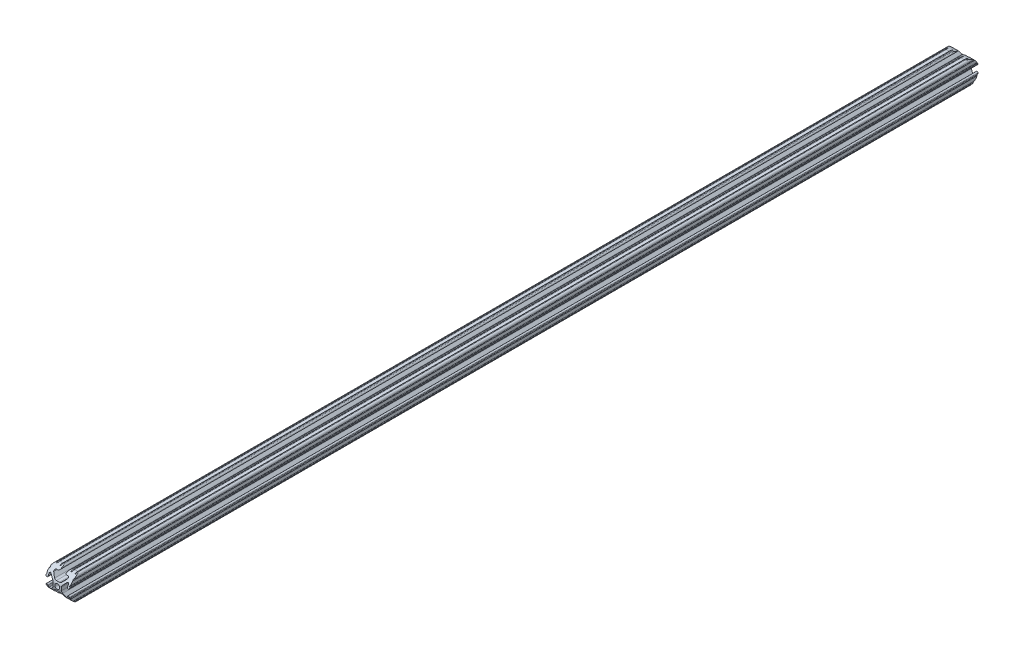
from build123d import *

# Parameters (mm, degrees)
SKETCH1_R           = 2.6035
BOSS_EXTRUDE1_DEPTH = 490.22
CUT_EXTRUDE1_DEPTH  = 26.4


with BuildPart() as part:
    # Sketch1 → Boss-Extrude1 (new body, symmetric)
    with BuildSketch(Plane(origin=(0, 0, -450.85), x_dir=(-1, 0, 0), z_dir=(0, 0, -1))):
        with BuildLine():
            Line((12.7, -9.5504), (12.7, -6.3330836))
            ThreePointArc((12.7, -6.3330836), (12.192, -5.8250836), (12.7, -5.3170836))
            Line((12.7, -5.3170836), (12.7, -4.3434))
            ThreePointArc((12.7, -4.3434), (11.5951, -3.2385), (10.4902, -4.3434))
            Line((10.4902, -4.3434), (10.4902, -6.474794456))
            ThreePointArc((10.4902, -6.474794456), (9.863006367, -7.413456061), (8.75577951, -7.193214945))
            Line((8.75577951, -7.193214945), (5.42573597, -3.863171405))
            ThreePointArc((5.42573597, -3.863171405), (4.737482484, -2.833127272), (4.4958, -1.618107374))
            Line((4.4958, -1.618107374), (4.4958, 1.618107374))
            ThreePointArc((4.4958, 1.618107374), (4.737482484, 2.833127272), (5.42573597, 3.863171405))
            Line((5.42573597, 3.863171405), (8.75577951, 7.193214945))
            ThreePointArc((8.75577951, 7.193214945), (9.863006367, 7.413456061), (10.4902, 6.474794456))
            Line((10.4902, 6.474794456), (10.4902, 4.343399971))
            ThreePointArc((10.4902, 4.343399971), (11.5951, 3.238499971), (12.7, 4.343399971))
            Line((12.7, 4.343399971), (12.7, 5.3170836))
            ThreePointArc((12.7, 5.3170836), (12.192, 5.8250836), (12.7, 6.3330836))
            Line((12.7, 6.3330836), (12.7, 9.5504))
            ThreePointArc((12.7, 9.5504), (12.192000006, 10.058323491), (12.699846982, 10.566399977))
            ThreePointArc((12.699846982, 10.566399977), (12.082522516, 12.082522516), (10.566399977, 12.699846982))
            ThreePointArc((10.566399977, 12.699846982), (10.058323491, 12.192000006), (9.5504, 12.7))
            Line((9.5504, 12.7), (6.3330836, 12.7))
            ThreePointArc((6.3330836, 12.7), (5.8250836, 12.192), (5.3170836, 12.7))
            Line((5.3170836, 12.7), (4.3434, 12.7))
            ThreePointArc((4.3434, 12.7), (3.2385, 11.5951), (4.3434, 10.4902))
            Line((4.3434, 10.4902), (6.474794456, 10.4902))
            ThreePointArc((6.474794456, 10.4902), (7.413456061, 9.863006367), (7.193214945, 8.75577951))
            Line((7.193214945, 8.75577951), (3.863171405, 5.42573597))
            ThreePointArc((3.863171405, 5.42573597), (2.833127272, 4.737482484), (1.618107374, 4.4958))
            Line((1.618107374, 4.4958), (-1.618107374, 4.4958))
            ThreePointArc((-1.618107374, 4.4958), (-2.833127272, 4.737482484), (-3.863171405, 5.42573597))
            Line((-3.863171405, 5.42573597), (-7.193214945, 8.75577951))
            ThreePointArc((-7.193214945, 8.75577951), (-7.413456061, 9.863006367), (-6.474794456, 10.4902))
            Line((-6.474794456, 10.4902), (-4.343399971, 10.4902))
            ThreePointArc((-4.343399971, 10.4902), (-3.238499971, 11.5951), (-4.343399971, 12.7))
            Line((-4.343399971, 12.7), (-5.3170836, 12.7))
            ThreePointArc((-5.3170836, 12.7), (-5.8250836, 12.192), (-6.3330836, 12.7))
            Line((-6.3330836, 12.7), (-9.5504, 12.7))
            ThreePointArc((-9.5504, 12.7), (-10.058323491, 12.192000006), (-10.566399977, 12.699846982))
            ThreePointArc((-10.566399977, 12.699846982), (-12.082522516, 12.082522516), (-12.699846982, 10.566399977))
            ThreePointArc((-12.699846982, 10.566399977), (-12.192000006, 10.058323491), (-12.7, 9.5504))
            Line((-12.7, 9.5504), (-12.7, 6.3330836))
            ThreePointArc((-12.7, 6.3330836), (-12.192, 5.8250836), (-12.7, 5.3170836))
            Line((-12.7, 5.3170836), (-12.7, 4.3434))
            ThreePointArc((-12.7, 4.3434), (-11.5951, 3.2385), (-10.4902, 4.3434))
            Line((-10.4902, 4.3434), (-10.4902, 6.474794456))
            ThreePointArc((-10.4902, 6.474794456), (-9.863006367, 7.413456061), (-8.75577951, 7.193214945))
            Line((-8.75577951, 7.193214945), (-5.42573597, 3.863171405))
            ThreePointArc((-5.42573597, 3.863171405), (-4.737482484, 2.833127272), (-4.4958, 1.618107374))
            Line((-4.4958, 1.618107374), (-4.4958, -1.618107374))
            ThreePointArc((-4.4958, -1.618107374), (-4.737482484, -2.833127272), (-5.42573597, -3.863171405))
            Line((-5.42573597, -3.863171405), (-8.75577951, -7.193214945))
            ThreePointArc((-8.75577951, -7.193214945), (-9.863006367, -7.413456061), (-10.4902, -6.474794456))
            Line((-10.4902, -6.474794456), (-10.4902, -4.343399971))
            ThreePointArc((-10.4902, -4.343399971), (-11.5951, -3.238499971), (-12.7, -4.343399971))
            Line((-12.7, -4.343399971), (-12.7, -5.3170836))
            ThreePointArc((-12.7, -5.3170836), (-12.192, -5.8250836), (-12.7, -6.3330836))
            Line((-12.7, -6.3330836), (-12.7, -9.5504))
            ThreePointArc((-12.7, -9.5504), (-12.192000006, -10.058323491), (-12.699846982, -10.566399977))
            ThreePointArc((-12.699846982, -10.566399977), (-12.082522516, -12.082522516), (-10.566399977, -12.699846982))
            ThreePointArc((-10.566399977, -12.699846982), (-10.058323491, -12.192000006), (-9.5504, -12.7))
            Line((-9.5504, -12.7), (-6.3330836, -12.7))
            ThreePointArc((-6.3330836, -12.7), (-5.8250836, -12.192), (-5.3170836, -12.7))
            Line((-5.3170836, -12.7), (-4.3434, -12.7))
            ThreePointArc((-4.3434, -12.7), (-3.2385, -11.5951), (-4.3434, -10.4902))
            Line((-4.3434, -10.4902), (-6.474794456, -10.4902))
            ThreePointArc((-6.474794456, -10.4902), (-7.413456061, -9.863006367), (-7.193214945, -8.75577951))
            Line((-7.193214945, -8.75577951), (-3.863171405, -5.42573597))
            ThreePointArc((-3.863171405, -5.42573597), (-2.833127272, -4.737482484), (-1.618107374, -4.4958))
            Line((-1.618107374, -4.4958), (1.618107374, -4.4958))
            ThreePointArc((1.618107374, -4.4958), (2.833127272, -4.737482484), (3.863171405, -5.42573597))
            Line((3.863171405, -5.42573597), (7.193214945, -8.75577951))
            ThreePointArc((7.193214945, -8.75577951), (7.413456061, -9.863006367), (6.474794456, -10.4902))
            Line((6.474794456, -10.4902), (4.343399971, -10.4902))
            ThreePointArc((4.343399971, -10.4902), (3.238499971, -11.5951), (4.343399971, -12.7))
            Line((4.343399971, -12.7), (5.3170836, -12.7))
            ThreePointArc((5.3170836, -12.7), (5.8250836, -12.192), (6.3330836, -12.7))
            Line((6.3330836, -12.7), (9.5504, -12.7))
            ThreePointArc((9.5504, -12.7), (10.058323491, -12.192000006), (10.566399977, -12.699846982))
            ThreePointArc((10.566399977, -12.699846982), (12.082522516, -12.082522516), (12.699846982, -10.566399977))
            ThreePointArc((12.699846982, -10.566399977), (12.192000006, -10.058323491), (12.7, -9.5504))
        make_face()
        Circle(SKETCH1_R, mode=Mode.SUBTRACT)
    extrude(amount=BOSS_EXTRUDE1_DEPTH, both=True)

    # Sketch2 → Cut-Extrude1 (cut, through all)
    with BuildSketch(Plane(origin=(12.7, 0, 0), x_dir=(0, 0, -1), z_dir=(1, 0, 0))):
        with BuildLine():
            Line((-26.773657599, 12.699846982), (-26.773657599, 15.407427294))
            Line((-26.773657599, 15.407427294), (-42.72426581, 14.835805087))
            Line((-42.72426581, 14.835805087), (-41.696320788, -13.848084546))
            Line((-41.696320788, -13.848084546), (-26.773657599, -13.848084546))
            Line((-26.773657599, -13.848084546), (-26.773657599, -12.699846982))
            ThreePointArc((-26.773657599, -12.699846982), (-39.473504581, 0), (-26.773657599, 12.699846982))
        make_face()
        with BuildLine():
            Line((928.370153018, 16.319168009), (945.357205325, 16.319168009))
            Line((945.357205325, 16.319168009), (945.357205325, -13.848084546))
            Line((945.357205325, -13.848084546), (928.370153018, -13.848084546))
            Line((928.370153018, -13.848084546), (928.370153018, -12.699846982))
            ThreePointArc((928.370153018, -12.699846982), (941.07, 0), (928.370153018, 12.699846982))
            Line((928.370153018, 12.699846982), (928.370153018, 16.319168009))
        make_face()
    extrude(amount=-CUT_EXTRUDE1_DEPTH, mode=Mode.SUBTRACT)


solid = part.part
